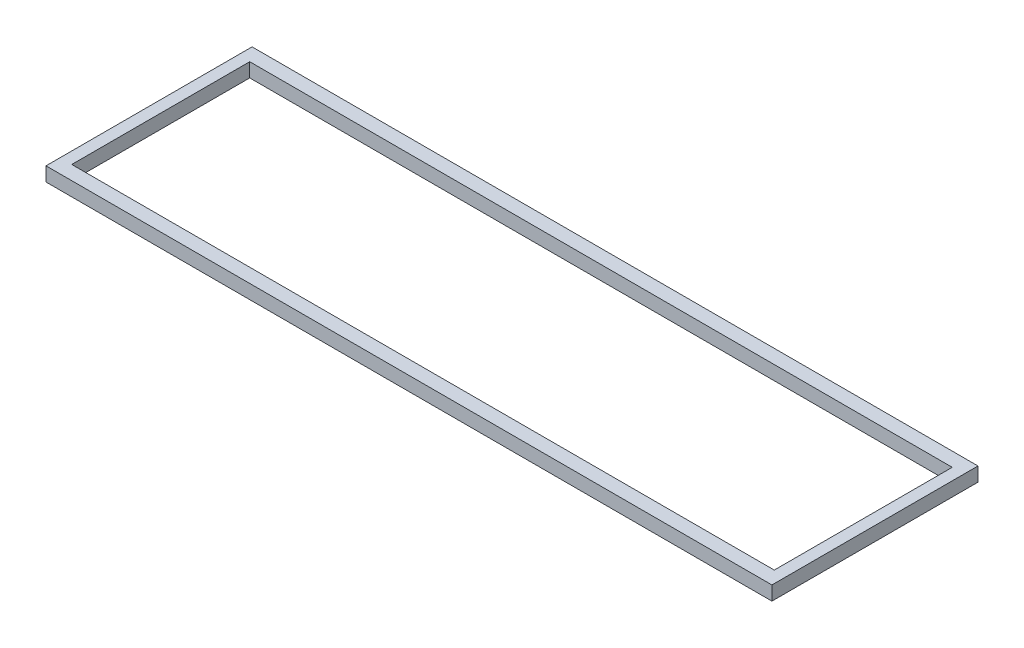
from build123d import *

# Parameters (mm, degrees)
SKETCH1_W           = 1550
SKETCH1_H           = 440
SKETCH1_W_2         = 1500
SKETCH1_H_2         = 380
BOSS_EXTRUDE1_DEPTH = 30


with BuildPart() as part:
    # Sketch1 → Boss-Extrude1 (new body)
    with BuildSketch(Plane(origin=(0, 0, 0), x_dir=(1, 0, 0), z_dir=(0, 1, 0))):
        with Locations((0, 121.424294269)):
            Rectangle(SKETCH1_W, SKETCH1_H)
        with Locations((0, 121.424294269)):
            Rectangle(SKETCH1_W_2, SKETCH1_H_2, mode=Mode.SUBTRACT)
    extrude(amount=BOSS_EXTRUDE1_DEPTH)


solid = part.part
